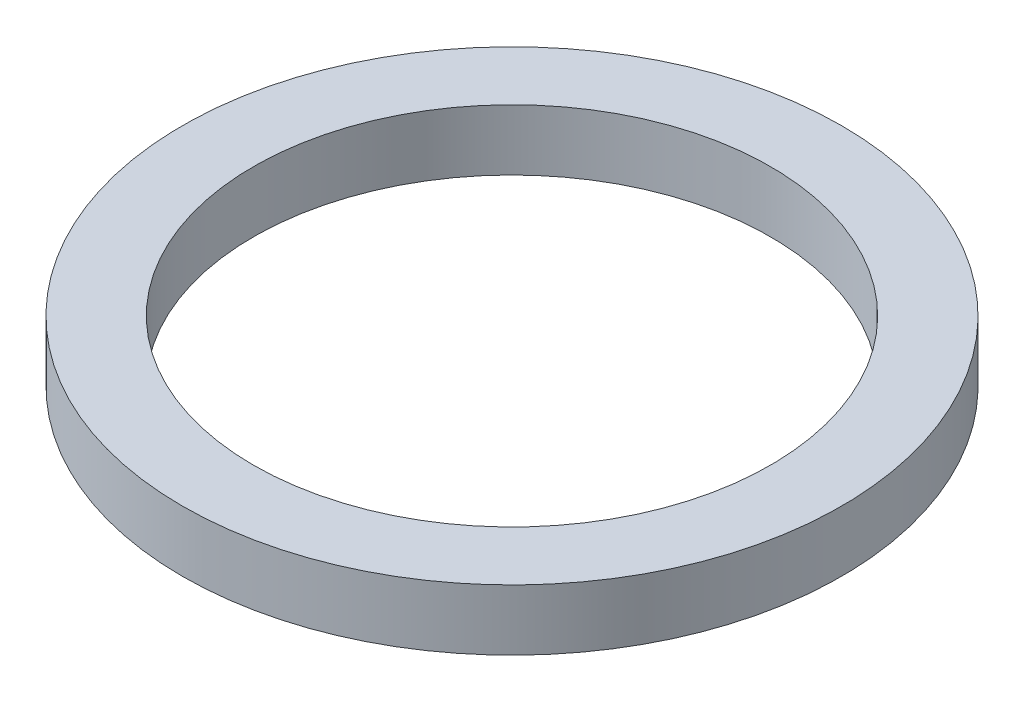
from build123d import *

# Parameters (mm, degrees)
SKETCH1_R      = 32.5
SKETCH1_R_2    = 25.5
EXTRUDE1_DEPTH = 6


with BuildPart() as part:
    # Sketch1 → Extrude1 (new body)
    with BuildSketch(Plane(origin=(0, 0, 0), x_dir=(1, 0, 0), z_dir=(0, 1, 0))):
        Circle(SKETCH1_R)
        Circle(SKETCH1_R_2, mode=Mode.SUBTRACT)
    extrude(amount=EXTRUDE1_DEPTH)


solid = part.part
